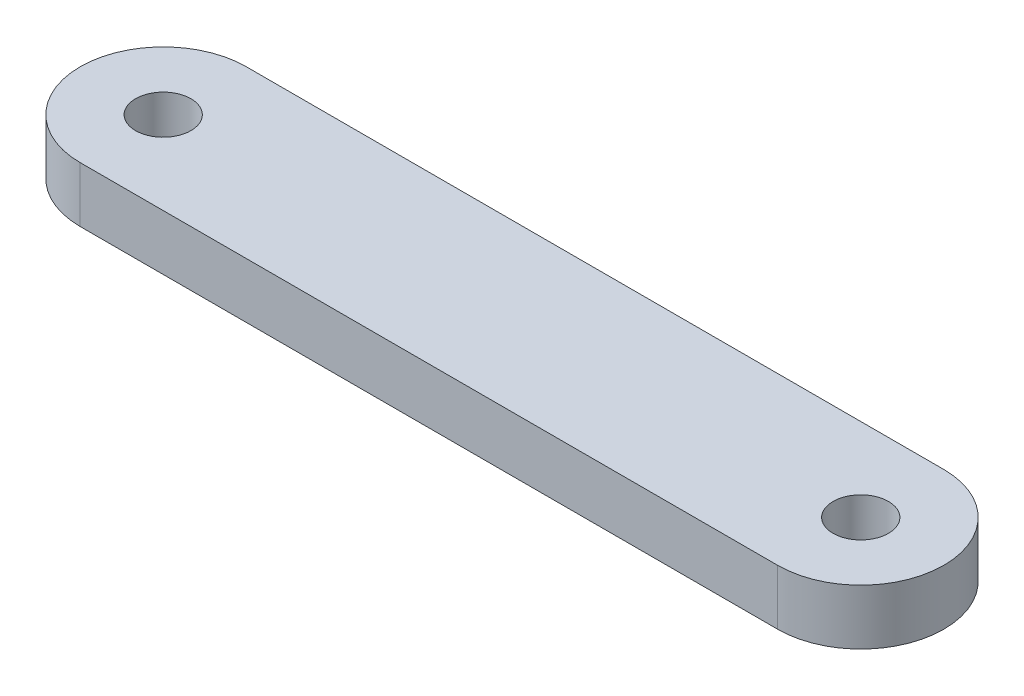
from build123d import *

# Parameters (mm, degrees)
CROQUIS1_R              = 1.5875
SALIENTE_EXTRUIR1_DEPTH = 3.175


with BuildPart() as part:
    # Croquis1 → Saliente-Extruir1 (new body)
    with BuildSketch(Plane(origin=(0, 0, 0), x_dir=(1, 0, 0), z_dir=(0, 1, 0))):
        with BuildLine():
            Line((-20, 0), (20, 0))
            ThreePointArc((20, 0), (24.7625, -4.7625), (20, -9.525))
            Line((20, -9.525), (-20, -9.525))
            ThreePointArc((-20, -9.525), (-24.7625, -4.7625), (-20, 0))
        make_face()
        with Locations((-20, -4.7625)):
            Circle(CROQUIS1_R, mode=Mode.SUBTRACT)
        with Locations((20, -4.7625)):
            Circle(CROQUIS1_R, mode=Mode.SUBTRACT)
    extrude(amount=SALIENTE_EXTRUIR1_DEPTH)


solid = part.part
